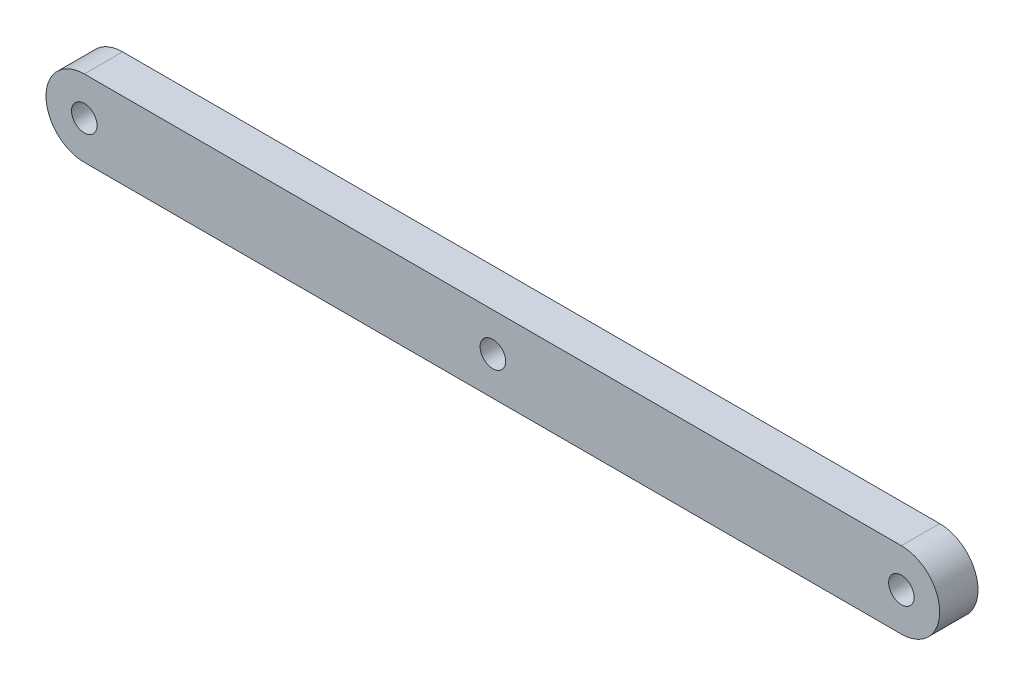
from build123d import *

# Parameters (mm, degrees)
SKETCH_1_R      = 1
EXTRUDE_1_DEPTH = 3


with BuildPart() as part:
    # 草图1 → 凸台-拉伸1 (new body)
    with BuildSketch(Plane.XY):
        with BuildLine():
            Line((-11, -2), (53, -2))
            ThreePointArc((53, -2), (56, 1), (53, 4))
            Line((53, 4), (-11, 4))
            ThreePointArc((-11, 4), (-14, 1), (-11, -2))
        make_face()
        with Locations((-11, 1)):
            Circle(SKETCH_1_R, mode=Mode.SUBTRACT)
        with Locations((53, 1)):
            Circle(SKETCH_1_R, mode=Mode.SUBTRACT)
        with Locations((21, 1)):
            Circle(SKETCH_1_R, mode=Mode.SUBTRACT)
    extrude(amount=EXTRUDE_1_DEPTH)


solid = part.part
